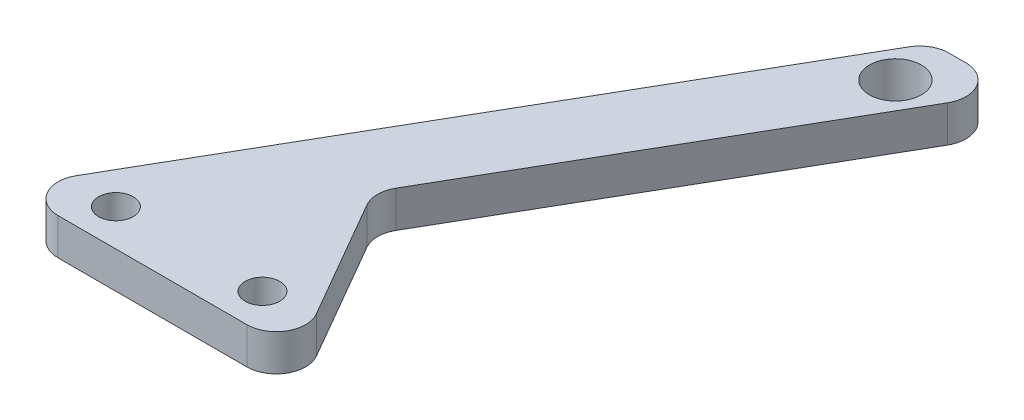
from build123d import *

# Parameters (mm, degrees)
SKETCH1_R           = 1.5
BOSS_EXTRUDE1_DEPTH = 3.175
SKETCH2_R           = 2.2479
CUT_EXTRUDE1_DEPTH  = 4.175
FILLET1_R           = 2.54


with BuildPart() as part:
    # Sketch1 → Boss-Extrude1 (new body)
    with BuildSketch(Plane(origin=(0, 0, 0), x_dir=(1, 0, 0), z_dir=(0, 1, 0))):
        Polygon((14.664696837, 25.4), (-14.664696837, -25.4), (10.500295474, -25.4), (1.583973528, -9.956477372), (21.997045256, 25.4), align=None)
        with Locations((-8.432200682, -22.225)):
            Circle(SKETCH1_R, mode=Mode.SUBTRACT)
        with Locations((4.267799318, -22.225)):
            Circle(SKETCH1_R, mode=Mode.SUBTRACT)
    extrude(amount=BOSS_EXTRUDE1_DEPTH)

    # Sketch2 → Cut-Extrude1 (cut, through all)
    with BuildSketch(Plane(origin=(0, 3.175, 0), x_dir=(1, 0, 0), z_dir=(0, 1, 0))):
        with Locations((15.826827494, 21.062869343)):
            Circle(SKETCH2_R)
    extrude(amount=-CUT_EXTRUDE1_DEPTH, mode=Mode.SUBTRACT)

    # Fillet1
    fillet1_edges = [part.edges().sort_by_distance(p)[0] for p in [
        (-14.664696837, 1.5875, 25.4),
        (14.664696837, 1.5875, -25.4),
        (21.997045256, 1.5875, -25.4),
        (1.583973528, 1.5875, 9.956477372),
        (10.500295474, 1.5875, 25.4),
    ]]
    fillet(fillet1_edges, radius=FILLET1_R)


solid = part.part
